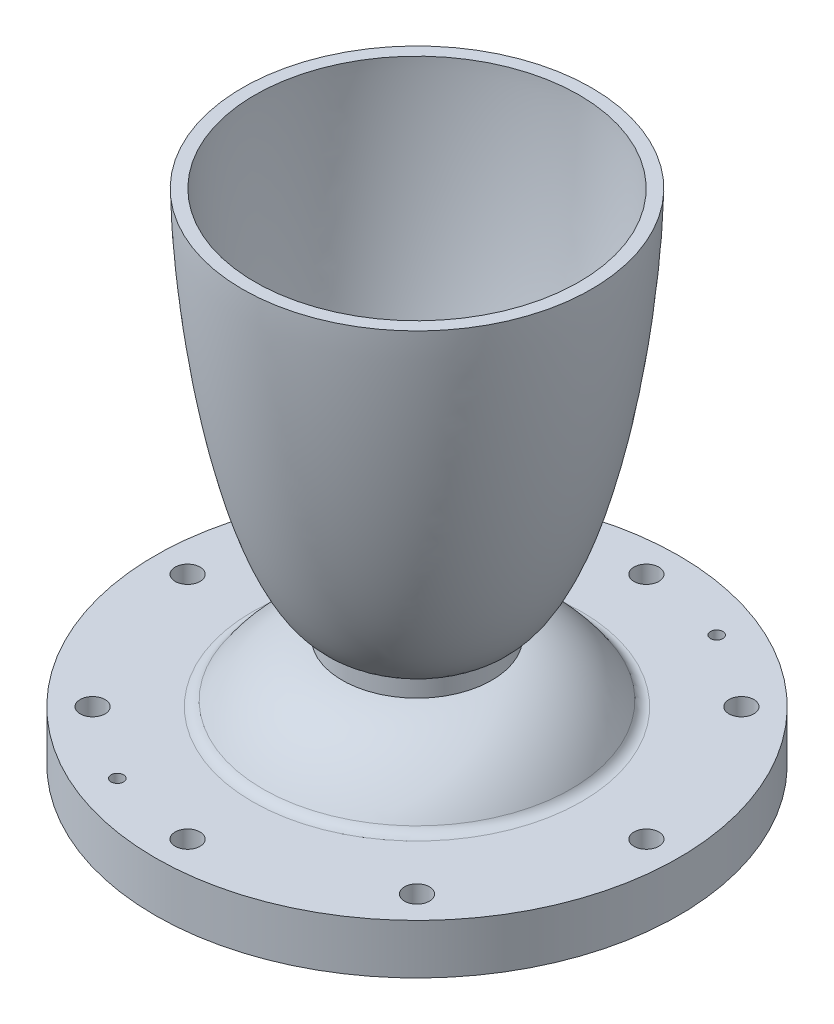
from build123d import *

# Parameters (mm, degrees)
CONVERGING_FILLET_R   = 3.175
BOLT_HOLES_D          = 6.35
BOLT_HOLES_DEPTH      = 12.7
BOLT_HOLES_TIP        = 1.907732465
PIN_HOLES_D           = 3.175
PIN_HOLES_DEPTH       = 100
PIN_HOLES_CBORE_D     = 6.35
PIN_HOLES_CBORE_DEPTH = 6.35


with BuildPart() as part:
    # Sketch1 → Main Revolve (revolve)
    with BuildSketch(Plane.XY):
        with BuildLine():
            Line((-9.517884855, 29.85426414), (-9.517884855, 31.004317662))
            ThreePointArc((-9.517884855, 31.004317662), (-10.387063469, 33.747209355), (-12.677340956, 35.488919819))
            add(Edge.make_bspline(
                [(-41.275, 127), (-41.268873036, 126.161357833), (-41.222997706, 124.484568363), (-41.073369126, 121.078528782), (-40.722786085, 115.949040077), (-40.170467422, 109.939618965), (-39.360849464, 103.059106185), (-38.382227863, 96.200616774), (-37.230570221, 89.368983139), (-35.895631241, 82.570619969), (-34.35912374, 75.814773558), (-32.593807355, 69.114550244), (-30.558516971, 62.490757957), (-28.191269221, 55.976383127), (-25.683140783, 50.29180013), (-23.125834222, 45.592543641), (-20.711209845, 42.055498174), (-18.720317843, 39.685916503), (-17.052831983, 38.103539579), (-15.746862259, 37.100217478), (-14.77072941, 36.476537732), (-14.077416444, 36.090491664), (-13.464775463, 35.797858298), (-13.037564762, 35.6215562), (-12.773284859, 35.523215456), (-12.677340956, 35.488919819)],
                knots=[0, 0, 0, 0, 0, 0.030811657, 0.061623313, 0.125250249, 0.188877076, 0.252503727, 0.31613061, 0.379757458, 0.443384315, 0.507011165, 0.570638032, 0.634264894, 0.697891611, 0.761518516, 0.798698062, 0.830511144, 0.855003573, 0.875012249, 0.882965592, 0.890918935, 0.897534321, 0.904149707, 0.907892787, 0.907892787, 0.907892787, 0.907892787, 0.907892787], degree=4))
            Line((-41.275, 127), (-44.449999999, 127))
            add(Edge.make_bspline(
                [(-44.449999999, 127), (-44.444048095, 126.089867786), (-44.399723494, 124.270031311), (-44.256170835, 120.604636062), (-43.921206973, 115.098603125), (-43.395046361, 108.666141993), (-42.624644612, 101.314791698), (-41.691159468, 93.9823601), (-40.588904101, 86.673339257), (-39.305520483, 79.393738689), (-37.819617038, 72.152599105), (-36.098890328, 64.963007024), (-34.092981802, 57.847082032), (-31.766198141, 50.972017381), (-29.315037347, 45.128649076), (-26.838138987, 40.469327818), (-24.570330265, 37.178251455), (-22.783120415, 35.132973657), (-21.307300799, 33.836487802), (-20.194653885, 33.074782772), (-19.515295281, 32.700466394), (-19.20577242, 32.548791321), (-19.05, 32.47725184)],
                knots=[0, 0, 0, 0, 0, 0.033160808, 0.066321616, 0.133644696, 0.20096779, 0.268290787, 0.335613842, 0.40293693, 0.470260007, 0.537583094, 0.604906139, 0.672229114, 0.739552316, 0.801869766, 0.835531618, 0.86410438, 0.88489762, 0.900577549, 0.906888404, 0.913134212, 0.913134212, 0.913134212, 0.913134212, 0.913134212], degree=4))
            Line((-19.05, 32.47725184), (-19.049999999, 28.042086726))
            add(Edge.make_bspline(
                [(-40.132930327, 12.7), (-40.045800084, 12.849795641), (-39.61063411, 13.587366211), (-38.787730692, 14.889107917), (-37.49639122, 16.700465362), (-35.743276325, 18.799808382), (-33.828362814, 20.752874932), (-31.755293022, 22.538171222), (-29.765599353, 23.963838921), (-27.959230186, 25.046029913), (-26.389400219, 25.845449005), (-25.088892975, 26.420387951), (-23.81412329, 26.906738928), (-22.507881474, 27.32323595), (-21.192562324, 27.667064424), (-20.14685077, 27.874680732), (-19.448803378, 27.987030694), (-19.080597755, 28.037915662), (-19.049999999, 28.042086726)],
                knots=[0.281378447, 0.281378447, 0.281378447, 0.281378447, 0.281378447, 0.29580073, 0.352648866, 0.409496837, 0.466344885, 0.523192931, 0.580040954, 0.636888987, 0.669796212, 0.698220237, 0.726644255, 0.755068258, 0.783492282, 0.811916293, 0.840340301, 0.842913615, 0.842913615, 0.842913615, 0.842913615, 0.842913615], degree=4))
            Line((-40.132930327, 12.7), (-66.675, 12.7))
            Line((-66.675, 12.7), (-66.675, 0))
            Line((-66.675, 0), (-41.275, 0))
            add(Edge.make_bspline(
                [(-41.275, 0), (-41.27404827, 0.048633732), (-41.270265816, 0.145822286), (-41.249886429, 0.420698051), (-41.184454538, 0.952068232), (-41.045697232, 1.718226005), (-40.803050388, 2.710615824), (-40.471359514, 3.795919992), (-40.073863441, 4.892829094), (-39.58250679, 6.074812663), (-38.909330489, 7.49520986), (-38.013176032, 9.129802593), (-36.850990459, 10.946036297), (-35.454742127, 12.816921248), (-33.931439219, 14.585782904), (-32.290383905, 16.245919147), (-30.54007116, 17.790421623), (-28.688732636, 19.212251207), (-26.744575764, 20.504343604), (-24.716209135, 21.659734331), (-22.61250234, 22.671709773), (-20.443220111, 23.533972634), (-18.496293348, 24.152467466), (-16.799886455, 24.58239915), (-15.513443264, 24.843608525), (-14.65819574, 24.990901269), (-14.086451577, 25.07519752), (-13.804404299, 25.113562074), (-13.666257288, 25.131526207)],
                knots=[0, 0, 0, 0, 0, 0.004014849, 0.008029698, 0.022747096, 0.044177712, 0.068247366, 0.092316927, 0.116386463, 0.140456137, 0.173883837, 0.222022894, 0.270162138, 0.318301135, 0.366440287, 0.41457937, 0.462718533, 0.510857613, 0.558996755, 0.607135854, 0.655274938, 0.703414059, 0.751553162, 0.775622711, 0.799692261, 0.811727037, 0.823244082, 0.823244082, 0.823244082, 0.823244082, 0.823244082], degree=4))
            ThreePointArc((-13.666257288, 25.131526207), (-10.702243662, 26.711285957), (-9.517884855, 29.85426414))
        make_face()
    revolve(axis=Axis((0, 0, 0), (0, 1, 0)))

    # Converging Fillet
    converging_fillet_edges = [part.edges().sort_by_distance(p)[0] for p in [
        (40.132930327, 12.7, 0),
    ]]
    fillet(converging_fillet_edges, radius=CONVERGING_FILLET_R)

    # Bolt Holes
    with Locations(Plane(origin=(0, 12.7, 0), x_dir=(1, 0, 0), z_dir=(0, 1, 0))):
        with Locations((-58.42, 0), (-41.309178157, 41.309178157), (0, 58.42), (41.309178157, 41.309178157), (58.42, 0), (41.309178157, -41.309178157), (0, -58.42), (-41.309178157, -41.309178157)):
            Hole(BOLT_HOLES_D / 2, depth=BOLT_HOLES_DEPTH)
            with Locations((0, 0, -(BOLT_HOLES_DEPTH + BOLT_HOLES_TIP / 2))):  # 118° drill point
                Cone(0, BOLT_HOLES_D / 2, BOLT_HOLES_TIP, mode=Mode.SUBTRACT)

    # Pin Holes
    with Locations(Plane(origin=(0, 0, 0), x_dir=(-1, 0, 0), z_dir=(0, -1, 0))):
        with Locations((-22.356366119, 53.973042289), (22.356366119, -53.973042289)):
            CounterBoreHole(PIN_HOLES_D / 2, PIN_HOLES_CBORE_D / 2, PIN_HOLES_CBORE_DEPTH, depth=PIN_HOLES_DEPTH)


solid = part.part
